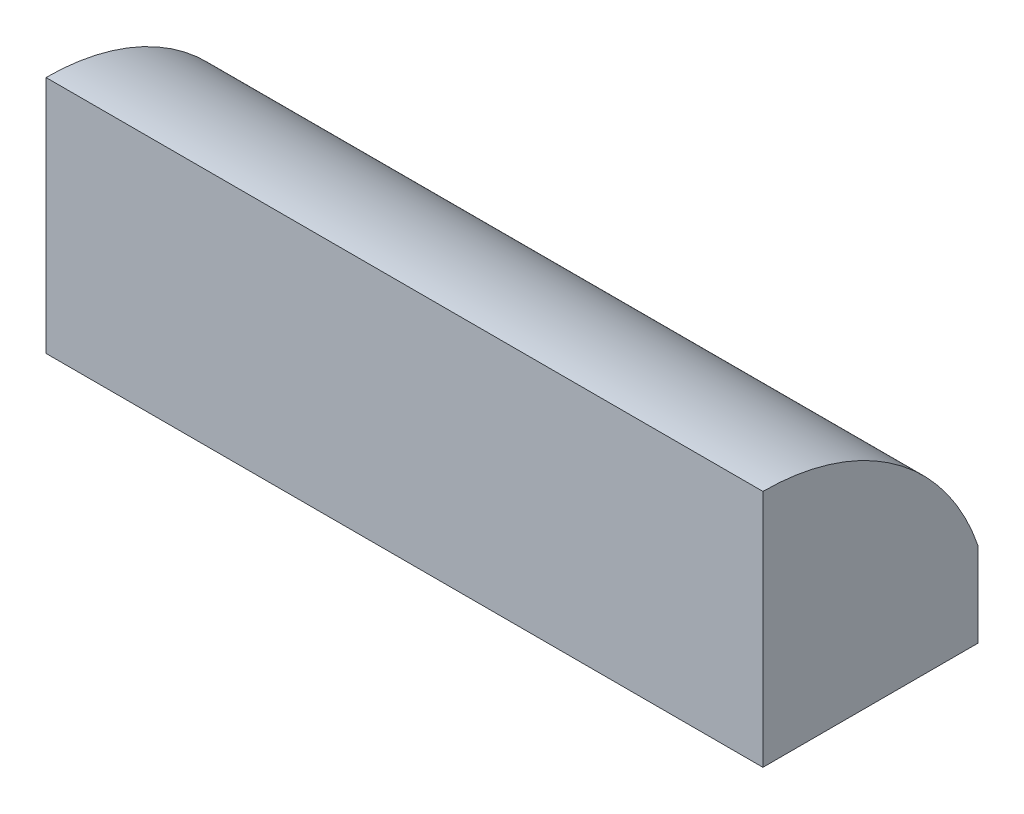
from build123d import *

# Parameters (mm, degrees)
SKETCH2_W           = 76.2
SKETCH2_H           = 22.86
BOSS_EXTRUDE1_DEPTH = 25.4
CUT_EXTRUDE1_DEPTH  = 77.2


with BuildPart() as part:
    # Sketch2 → Boss-Extrude1 (new body)
    with BuildSketch(Plane(origin=(0, 0, 0), x_dir=(1, 0, 0), z_dir=(0, 1, 0))):
        with Locations((27.371842105, -1.153026316)):
            Rectangle(SKETCH2_W, SKETCH2_H)
    extrude(amount=BOSS_EXTRUDE1_DEPTH)

    # Sketch3 → Cut-Extrude1 (cut, through all)
    with BuildSketch(Plane(origin=(65.471842105, 0, 0), x_dir=(0, 0, -1), z_dir=(1, 0, 0))):
        with BuildLine():
            Line((-12.583026316, 25.4), (10.276973684, 25.4))
            Line((10.276973684, 25.4), (10.276973684, 8.963446719))
            ThreePointArc((10.276973684, 8.963446719), (1.494792086, 20.864315909), (-12.583026316, 25.4))
        make_face()
    extrude(amount=-CUT_EXTRUDE1_DEPTH, mode=Mode.SUBTRACT)


solid = part.part
